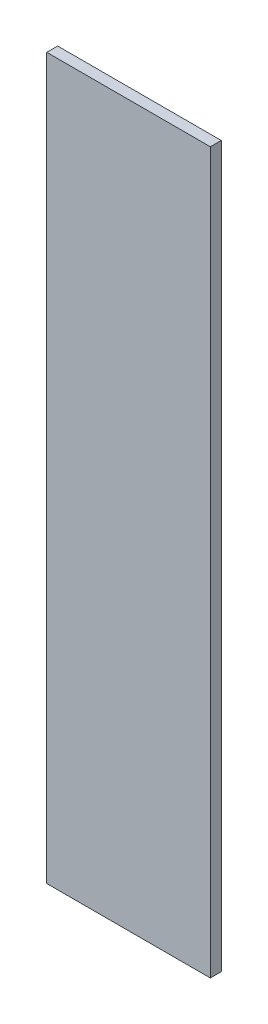
from build123d import *

# Parameters (mm, degrees)
SKETCH1_W           = 95.25
SKETCH1_H           = 419.1
BOSS_EXTRUDE1_DEPTH = 6.35


with BuildPart() as part:
    # Sketch1 → Boss-Extrude1 (new body)
    with BuildSketch(Plane.XY):
        with Locations((47.625, 222.25)):
            Rectangle(SKETCH1_W, SKETCH1_H)
    extrude(amount=BOSS_EXTRUDE1_DEPTH)


solid = part.part
